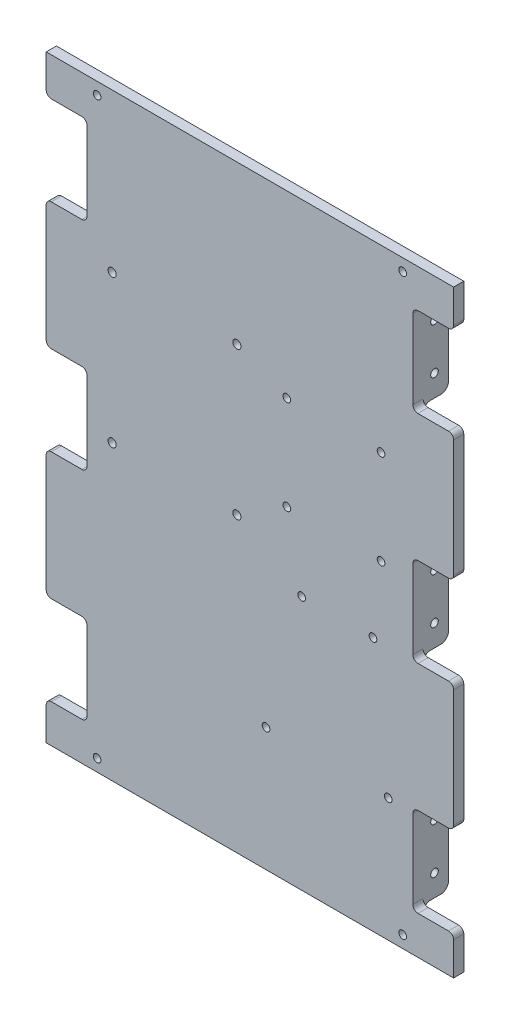
from build123d import *

# Parameters (mm, degrees)
BOSS_EXTRUDE1_DEPTH = 4
SKETCH4_W           = 10
SKETCH4_H           = 35
BOSS_EXTRUDE3_DEPTH = 14
SKETCH6_R           = 1.5
CUT_EXTRUDE1_DEPTH  = 128
FILLET2_R           = 3
FILLET3_R           = 2
SKETCH7_W           = 30
SKETCH7_H           = 81
BOSS_EXTRUDE4_DEPTH = 7
FILLET4_R           = 4
SKETCH8_R           = 1.5
CUT_EXTRUDE2_DEPTH  = 15
SKETCH9_R           = 1.5
SKETCH9_R_2         = 1.6
CUT_EXTRUDE3_DEPTH  = 15
CUT_EXTRUDE4_DEPTH  = 10


with BuildPart() as part:
    # Sketch1 → Boss-Extrude1 (new body)
    with BuildSketch(Plane.XY):
        Polygon((80, 25), (80, -25), (64, -25), (64, -60), (80, -60), (80, -75), (-80, -75), (-80, -60), (-64, -60), (-64, -25), (-80, -25), (-80, 25), (-64, 25), (-64, 60), (-80, 60), (-80, 110), (-64, 110), (-64, 145), (-80, 145), (-80, 160), (80, 160), (80, 145), (64, 145), (64, 110), (80, 110), (80, 60), (64, 60), (64, 25), align=None)
    extrude(amount=-BOSS_EXTRUDE1_DEPTH)

    # Sketch4 → Boss-Extrude3 (add)
    with BuildSketch(Plane.XY):
        with Locations((-59, -42.5)):
            Rectangle(SKETCH4_W, SKETCH4_H)
        with Locations((59, 42.5)):
            Rectangle(SKETCH4_W, SKETCH4_H)
        with Locations((59, -42.5)):
            Rectangle(SKETCH4_W, SKETCH4_H)
        with Locations((-59, 42.5)):
            Rectangle(SKETCH4_W, SKETCH4_H)
        with Locations((-59, 127.5)):
            Rectangle(SKETCH4_W, SKETCH4_H)
        with Locations((59, 127.5)):
            Rectangle(SKETCH4_W, SKETCH4_H)
    extrude(amount=-BOSS_EXTRUDE3_DEPTH)

    # Sketch6 → Cut-Extrude1 (cut)
    with BuildSketch(Plane(origin=(64, 0, 0), x_dir=(0, 0, -1), z_dir=(1, 0, 0))):
        with Locations((8.5, -51.5)):
            Circle(SKETCH6_R)
        with Locations((8.5, -33.5)):
            Circle(SKETCH6_R)
        with Locations((8.5, 33.5)):
            Circle(SKETCH6_R)
        with Locations((8.5, 51.5)):
            Circle(SKETCH6_R)
        with Locations((8.5, 118.5)):
            Circle(SKETCH6_R)
        with Locations((8.5, 136.5)):
            Circle(SKETCH6_R)
    extrude(amount=-CUT_EXTRUDE1_DEPTH, mode=Mode.SUBTRACT)

    # Fillet2
    fillet2_edges = [part.edges().sort_by_distance(p)[0] for p in [
        (-59, -25, -4),
        (-59, -60, -4),
        (59, -60, -14),
        (59, -25, -14),
        (59, -60, -4),
        (59, -25, -4),
        (-59, 60, -14),
        (-59, 25, -14),
        (-59, 60, -4),
        (-59, 25, -4),
        (-59, 145, -14),
        (-59, 110, -14),
        (-59, 145, -4),
        (-59, 110, -4),
        (59, 110, -14),
        (59, 145, -14),
        (59, 110, -4),
        (59, 145, -4),
        (59, 25, -14),
        (59, 60, -14),
        (59, 25, -4),
        (59, 60, -4),
        (-59, -25, -14),
        (-59, -60, -14),
    ]]
    fillet(fillet2_edges, radius=FILLET2_R)

    # Fillet3
    fillet3_edges = [part.edges().sort_by_distance(p)[0] for p in [
        (-64, -60, -2),
        (-64, -25, -2),
        (-80, -25, -2),
        (-80, 25, -2),
        (-64, 25, -2),
        (-64, 60, -2),
        (-80, 60, -2),
        (-80, 110, -2),
        (-64, 110, -2),
        (-64, 145, -2),
        (-80, 145, -2),
        (80, 145, -2),
        (64, 145, -2),
        (64, 110, -2),
        (80, 110, -2),
        (80, 60, -2),
        (64, 60, -2),
        (64, 25, -2),
        (80, 25, -2),
        (80, -25, -2),
        (64, -25, -2),
        (64, -60, -2),
        (80, -60, -2),
        (-80, -60, -2),
    ]]
    fillet(fillet3_edges, radius=FILLET3_R)

    # Sketch7 → Boss-Extrude4 (add)
    with BuildSketch(Plane(origin=(0, 0, -4), x_dir=(-1, 0, 0), z_dir=(0, 0, -1))):
        Polygon((36.5, 125.5), (64, 125.5), (64, 129.5), (0, 129.5), (-64, 129.5), (-64, 125.5), (-36.5, 125.5), (-36.5, 44.5), (-64, 44.5), (-64, 40.5), (-36.5, 40.5), (-36.5, -40.5), (-64, -40.5), (-64, -44.5), (0, -44.5), (64, -44.5), (64, -40.5), (36.5, -40.5), (36.5, 40.5), (64, 40.5), (64, 44.5), (36.5, 44.5), align=None)
        with Locations((17.5, 85)):
            Rectangle(SKETCH7_W, SKETCH7_H, mode=Mode.SUBTRACT)
        with Locations((17.5, 0)):
            Rectangle(SKETCH7_W, SKETCH7_H, mode=Mode.SUBTRACT)
        with Locations((-17.5, 0)):
            Rectangle(SKETCH7_W, SKETCH7_H, mode=Mode.SUBTRACT)
        with Locations((-17.5, 85)):
            Rectangle(SKETCH7_W, SKETCH7_H, mode=Mode.SUBTRACT)
    extrude(amount=BOSS_EXTRUDE4_DEPTH)

    # Fillet4
    fillet4_edges = [part.edges().sort_by_distance(p)[0] for p in [
        (54, 129.5, -7.5),
        (54, 125.5, -7.5),
        (-54, 125.5, -7.5),
        (-54, 44.5, -7.5),
        (54, -44.5, -7.5),
        (54, -40.5, -7.5),
        (-54, -40.5, -7.5),
        (54, 40.5, -7.5),
        (54, 44.5, -7.5),
        (-54, -44.5, -7.5),
        (-54, 129.5, -7.5),
        (36.5, 125.5, -7.5),
        (36.5, 44.5, -7.5),
        (36.5, 40.5, -7.5),
        (36.5, -40.5, -7.5),
        (-36.5, -40.5, -7.5),
        (-36.5, 40.5, -7.5),
        (-36.5, 44.5, -7.5),
        (-36.5, 125.5, -7.5),
        (-2.5, -40.5, -7.5),
        (-32.5, -40.5, -7.5),
        (-32.5, 40.5, -7.5),
        (-2.5, 44.5, -7.5),
        (-32.5, 44.5, -7.5),
        (-32.5, 125.5, -7.5),
        (-2.5, 125.5, -7.5),
        (32.5, -40.5, -7.5),
        (2.5, -40.5, -7.5),
        (2.5, 40.5, -7.5),
        (32.5, 40.5, -7.5),
        (32.5, 44.5, -7.5),
        (2.5, 44.5, -7.5),
        (2.5, 125.5, -7.5),
        (32.5, 125.5, -7.5),
    ]]
    fillet(fillet4_edges, radius=FILLET4_R)

    # Sketch8 → Cut-Extrude2 (cut, through all)
    with BuildSketch(Plane.XY):
        with Locations((-60, 155.25)):
            Circle(SKETCH8_R)
        with Locations((60, 155.25)):
            Circle(SKETCH8_R)
        with Locations((-60, -70.25)):
            Circle(SKETCH8_R)
        with Locations((60, -70.25)):
            Circle(SKETCH8_R)
    extrude(amount=-CUT_EXTRUDE2_DEPTH, mode=Mode.SUBTRACT)

    # Sketch9 → Cut-Extrude3 (cut, through all)
    with BuildSketch(Plane.XY):
        with Locations((51.5, 89.5)):
            Circle(SKETCH9_R)
        with Locations((51.5, 52.5)):
            Circle(SKETCH9_R)
        with Locations((14.5, 52.5)):
            Circle(SKETCH9_R)
        with Locations((14.5, 89.5)):
            Circle(SKETCH9_R)
        with Locations((-5.109510439, 97.973520729)):
            Circle(SKETCH9_R_2)
        with Locations((-54.109510439, 97.973520729)):
            Circle(SKETCH9_R_2)
        with Locations((-54.109510439, 39.973520729)):
            Circle(SKETCH9_R_2)
        with Locations((-5.109510439, 39.973520729)):
            Circle(SKETCH9_R_2)
        with Locations((48.338781935, 24.946084547)):
            Circle(SKETCH9_R)
        with Locations((20.338781935, 24.946084547)):
            Circle(SKETCH9_R)
        with Locations((6.338781935, -26.553915453)):
            Circle(SKETCH9_R)
        with Locations((54.338781935, -26.553915453)):
            Circle(SKETCH9_R)
    extrude(amount=-CUT_EXTRUDE3_DEPTH, mode=Mode.SUBTRACT)

    # Sketch10 → Cut-Extrude4 (cut)
    with BuildSketch(Plane(origin=(0, 0, -4), x_dir=(-1, 0, 0), z_dir=(0, 0, -1))):
        Polygon((2.222759093, 39.973520729), (3.666134766, 37.473520729), (6.552886112, 37.473520729), (7.996261785, 39.973520729), (6.552886112, 42.473520729), (3.666134766, 42.473520729), align=None)
        Polygon((56.996261785, 39.973520729), (55.552886112, 42.473520729), (52.666134766, 42.473520729), (51.222759093, 39.973520729), (52.666134766, 37.473520729), (55.552886112, 37.473520729), align=None)
        Polygon((-54.338781935, -23.667164107), (-56.838781935, -25.11053978), (-56.838781935, -27.997291126), (-54.338781935, -29.440666799), (-51.838781935, -27.997291126), (-51.838781935, -25.11053978), align=None)
    extrude(amount=CUT_EXTRUDE4_DEPTH, mode=Mode.SUBTRACT)


solid = part.part
